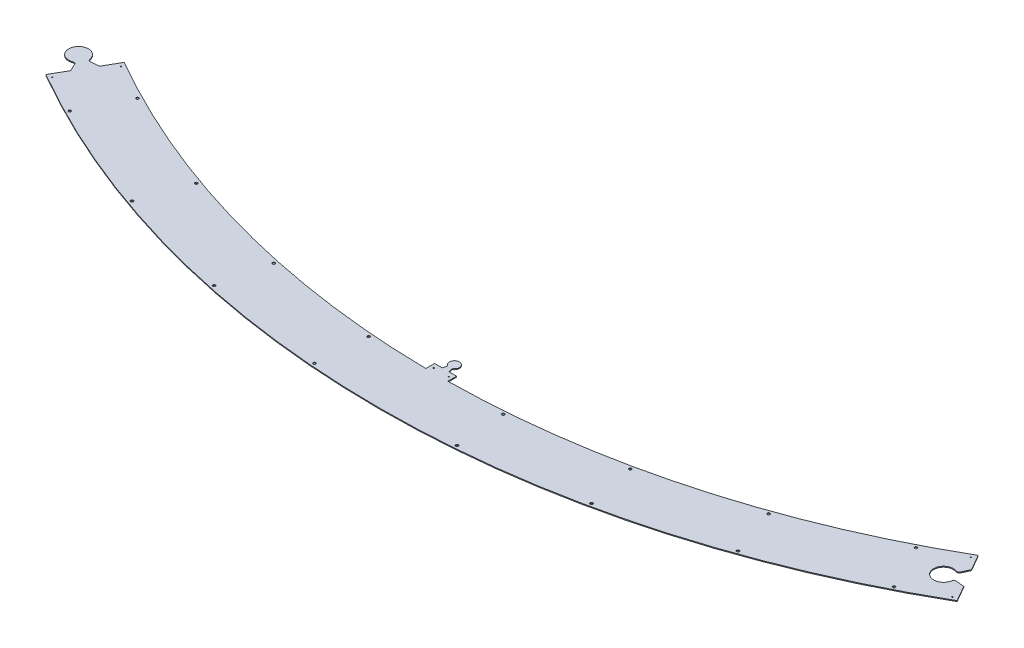
from build123d import *

# Parameters (mm, degrees)
SKETCH1_R           = 1.25
SKETCH1_R_2         = 3
BOSS_EXTRUDE2_DEPTH = 2
CUT_EXTRUDE2_DEPTH  = 2
BOSS_EXTRUDE3_DEPTH = 2
FILLET1_R           = 1


with BuildPart() as part:
    # Sketch1 → Boss-Extrude2 (new body)
    with BuildSketch(Plane(origin=(0, 0, 0), x_dir=(1, 0, 0), z_dir=(0, 1, 0))):
        with BuildLine():
            Line((967.5, -1675.759156323), (1032.5, -1788.342458815))
            ThreePointArc((1032.5, -1788.342458815), (0, -2065), (-1032.5, -1788.342458815))
            Line((-1032.5, -1788.342458815), (-967.5, -1675.759156323))
            ThreePointArc((-967.5, -1675.759156323), (-512.878726771, -1865.792167318), (-25, -1934.838494552))
            Line((-25, -1934.838494552), (-25, -1915))
            Line((-25, -1915), (25, -1915))
            Line((25, -1915), (25, -1934.838494552))
            ThreePointArc((25, -1934.838494552), (512.878726771, -1865.792167318), (967.5, -1675.759156323))
        make_face()
        with Locations((-17, -1925)):
            Circle(SKETCH1_R, mode=Mode.SUBTRACT)
        with Locations((17, -1925)):
            Circle(SKETCH1_R, mode=Mode.SUBTRACT)
        with Locations((962.839745962, -1687.687359553)):
            Circle(SKETCH1_R, mode=Mode.SUBTRACT)
        with Locations((1019.839745962, -1786.414255585)):
            Circle(SKETCH1_R, mode=Mode.SUBTRACT)
        with Locations((686.598290691, -1939.028567923)):
            Circle(SKETCH1_R_2, mode=Mode.SUBTRACT)
        with Locations((933.81836271, -1832.820849255)):
            Circle(SKETCH1_R_2, mode=Mode.SUBTRACT)
        with Locations((427.630331557, -2012.058970193)):
            Circle(SKETCH1_R_2, mode=Mode.SUBTRACT)
        with Locations((-1019.839745962, -1786.414255585)):
            Circle(SKETCH1_R, mode=Mode.SUBTRACT)
        with Locations((-962.839745962, -1687.687359553)):
            Circle(SKETCH1_R, mode=Mode.SUBTRACT)
        with Locations((161.345498888, -2050.662485634)):
            Circle(SKETCH1_R_2, mode=Mode.SUBTRACT)
        with Locations((882.06566784, -1731.244973312)):
            Circle(SKETCH1_R_2, mode=Mode.SUBTRACT)
        with Locations((648.546659607, -1831.566605481)):
            Circle(SKETCH1_R_2, mode=Mode.SUBTRACT)
        with Locations((403.930838218, -1900.549625223)):
            Circle(SKETCH1_R_2, mode=Mode.SUBTRACT)
        with Locations((152.403648196, -1937.013713946)):
            Circle(SKETCH1_R_2, mode=Mode.SUBTRACT)
        with Locations((-152.403648196, -1937.013713946)):
            Circle(SKETCH1_R_2, mode=Mode.SUBTRACT)
        with Locations((-403.930838218, -1900.549625223)):
            Circle(SKETCH1_R_2, mode=Mode.SUBTRACT)
        with Locations((-648.546659607, -1831.566605481)):
            Circle(SKETCH1_R_2, mode=Mode.SUBTRACT)
        with Locations((-882.06566784, -1731.244973312)):
            Circle(SKETCH1_R_2, mode=Mode.SUBTRACT)
        with Locations((-161.345498888, -2050.662485634)):
            Circle(SKETCH1_R_2, mode=Mode.SUBTRACT)
        with Locations((-427.630331557, -2012.058970193)):
            Circle(SKETCH1_R_2, mode=Mode.SUBTRACT)
        with Locations((-933.81836271, -1832.820849255)):
            Circle(SKETCH1_R_2, mode=Mode.SUBTRACT)
        with Locations((-686.598290691, -1939.028567923)):
            Circle(SKETCH1_R_2, mode=Mode.SUBTRACT)
    extrude(amount=BOSS_EXTRUDE2_DEPTH)

    # Sketch2 → Cut-Extrude2 (cut)
    with BuildSketch(Plane(origin=(0, 2, 0), x_dir=(1, 0, 0), z_dir=(0, 1, 0))):
        with BuildLine():
            Line((992.847509482, -1751.163204556), (1012.002075382, -1752.839011927))
            Line((1012.002075382, -1752.839011927), (987.997924618, -1711.262603211))
            Line((987.997924618, -1711.262603211), (979.871933423, -1728.688847565))
            ThreePointArc((979.871933423, -1728.688847565), (977.197403711, -1731.218117373), (973.516351606, -1731.231168973))
            ThreePointArc((973.516351606, -1731.231168973), (945.994067118, -1763.231147456), (987.468003649, -1755.396139162))
            ThreePointArc((987.468003649, -1755.396139162), (989.319832718, -1752.214780325), (992.847509482, -1751.163204556))
        make_face()
    extrude(amount=-CUT_EXTRUDE2_DEPTH, mode=Mode.SUBTRACT)

    # Sketch4 → Boss-Extrude3 (add)
    with BuildSketch(Plane(origin=(0, 2, 0), x_dir=(1, 0, 0), z_dir=(0, 1, 0))):
        with BuildLine():
            Line((-1007.152490518, -1712.938410582), (-987.997924618, -1711.262603211))
            Line((-987.997924618, -1711.262603211), (-1012.002075382, -1752.839011927))
            Line((-1012.002075382, -1752.839011927), (-1020.128066577, -1735.412767573))
            ThreePointArc((-1020.128066577, -1735.412767573), (-1022.802596289, -1732.883497764), (-1026.483648394, -1732.870446165))
            ThreePointArc((-1026.483648394, -1732.870446165), (-1054.005932882, -1700.870467681), (-1012.531996351, -1708.705475976))
            ThreePointArc((-1012.531996351, -1708.705475976), (-1010.680167282, -1711.886834812), (-1007.152490518, -1712.938410582))
        make_face()
        with BuildLine():
            Line((5.48633271, -1906.815018385), (7.679491924, -1915))
            Line((7.679491924, -1915), (-7.679491924, -1915))
            Line((-7.679491924, -1915), (-5.48633271, -1906.815018385))
            ThreePointArc((-5.48633271, -1906.815018385), (-5.549842721, -1905.31863757), (-6.457260037, -1904.127091147))
            ThreePointArc((-6.457260037, -1904.127091147), (0, -1883.819660113), (6.457260037, -1904.127091147))
            ThreePointArc((6.457260037, -1904.127091147), (5.549842721, -1905.31863757), (5.48633271, -1906.815018385))
        make_face()
    extrude(amount=-BOSS_EXTRUDE3_DEPTH)

    # Fillet1
    fillet1_edges = [part.edges().sort_by_distance(p)[0] for p in [
        (-1032.5, 1, 1788.342458815),
        (-967.5, 1, 1675.759156323),
        (-25, 1, 1915),
        (25, 1, 1915),
        (967.5, 1, 1675.759156323),
        (1032.5, 1, 1788.342458815),
    ]]
    fillet(fillet1_edges, radius=FILLET1_R)


solid = part.part
